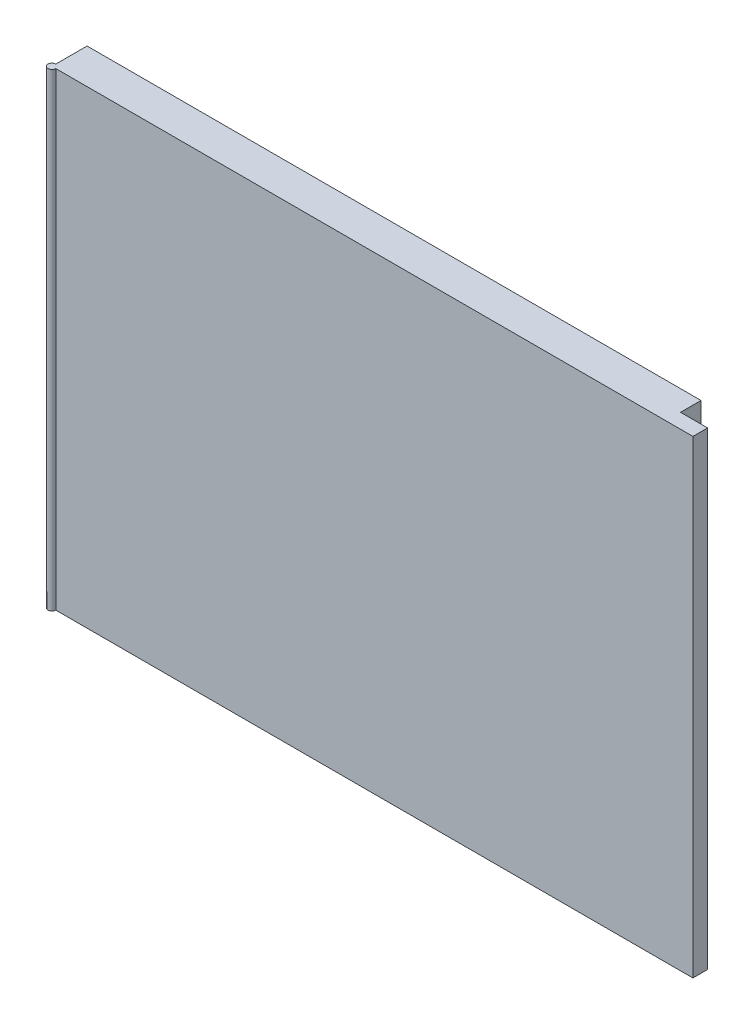
from build123d import *

# Parameters (mm, degrees)
EXTRUDE_1_DEPTH = 600


with BuildPart() as part:
    # Эскиз1 → Бобышка-Вытянуть1 (new body)
    with BuildSketch(Plane(origin=(0, 0, 0), x_dir=(1, 0, 0), z_dir=(0, 1, 0))):
        with BuildLine():
            Line((5, 0), (820, 0))
            Line((820, 0), (820, 18.800386004))
            Line((820, 18.800386004), (785.363179306, 18.800386004))
            Line((785.363179306, 18.800386004), (785.363179306, 45))
            Line((785.363179306, 45), (0, 45))
            Line((0, 45), (0, 5))
            ThreePointArc((0, 5), (-3.535533906, -3.535533906), (5, 0))
        make_face()
    extrude(amount=EXTRUDE_1_DEPTH)


solid = part.part
